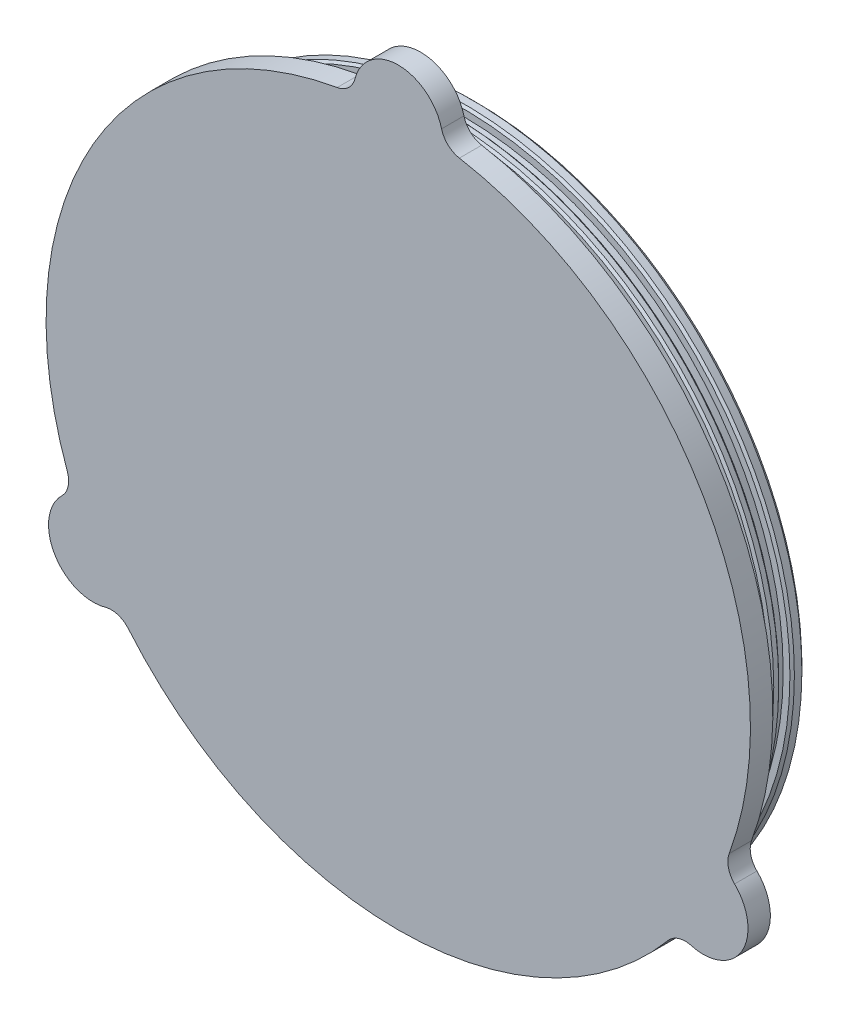
from build123d import *

# Parameters (mm, degrees)
SKETCH1_R          = 100.0125
EXTRUDE1_DEPTH     = 6.35
SKETCH2_R          = 93.6625
EXTRUDE2_DEPTH     = 15.875
SKETCH3_R          = 87.3125
CUT_EXTRUDE1_DEPTH = 15.875
SKETCH4_W          = 3.175
SKETCH4_H          = 2.54
CHAMFER1_SIZE      = 1.27
EXTRUDE3_DEPTH     = 6.35
CHAMFER2_SIZE      = 0.635
FILLET1_R          = 6.35


with BuildPart() as part:
    # Sketch1 → Extrude1 (new body)
    with BuildSketch(Plane.XY):
        Circle(SKETCH1_R)
    extrude(amount=EXTRUDE1_DEPTH)

    # Sketch2 → Extrude2 (add)
    with BuildSketch(Plane(origin=(0, 0, 0), x_dir=(-1, 0, 0), z_dir=(0, 0, -1))):
        Circle(SKETCH2_R)
    extrude(amount=EXTRUDE2_DEPTH)

    # Sketch3 → Cut-Extrude1 (cut)
    with BuildSketch(Plane(origin=(0, 0, -15.875), x_dir=(-1, 0, 0), z_dir=(0, 0, -1))):
        Circle(SKETCH3_R)
    extrude(amount=-CUT_EXTRUDE1_DEPTH, mode=Mode.SUBTRACT)

    # Sketch4 → Cut-Revolve1 (revolve, cut)
    with BuildSketch(Plane(origin=(0, 0, 0), x_dir=(0, 0, -1), z_dir=(1, 0, 0))):
        with Locations((4.395911794, 92.3925)):
            Rectangle(SKETCH4_W, SKETCH4_H)
        with Locations((10.251990741, 92.3925)):
            Rectangle(SKETCH4_W, SKETCH4_H)
    revolve(axis=Axis((0, 0, 0), (0, 0, -1)), mode=Mode.SUBTRACT)

    # Chamfer1
    chamfer1_edges = [part.edges().sort_by_distance(p)[0] for p in [
        (93.6625, 0, -15.875),
    ]]
    chamfer(chamfer1_edges, length=CHAMFER1_SIZE)

    # Sketch8 → Extrude3 (add)
    with BuildSketch(Plane.XY.offset(6.35)):
        with BuildLine():
            ThreePointArc((-12.674375762, 99.206150794), (0, 112.7125), (12.674375762, 99.206150794))
            ThreePointArc((12.674375762, 99.206150794), (0, 100.0125), (-12.674375762, 99.206150794))
        make_face()
        with BuildLine():
            ThreePointArc((92.25223468, -38.62674401), (97.611888324, -56.35625), (79.577858918, -60.579406784))
            ThreePointArc((79.577858918, -60.579406784), (86.613365696, -50.00625), (92.25223468, -38.62674401))
        make_face()
        with BuildLine():
            ThreePointArc((-92.25223468, -38.62674401), (-97.611888324, -56.35625), (-79.577858918, -60.579406784))
            ThreePointArc((-79.577858918, -60.579406784), (-86.613365696, -50.00625), (-92.25223468, -38.62674401))
        make_face()
    extrude(amount=-EXTRUDE3_DEPTH)

    # Chamfer2
    chamfer2_edges = [part.edges().sort_by_distance(p)[0] for p in [
        (93.6625, 0, -2.808411794),
        (93.6625, 0, -5.983411794),
        (93.6625, 0, -8.664490741),
        (93.6625, 0, -11.839490741),
    ]]
    chamfer(chamfer2_edges, length=CHAMFER2_SIZE)

    # Fillet1
    fillet1_edges = [part.edges().sort_by_distance(p)[0] for p in [
        (12.674375762, 99.206150794, 3.175),
        (-12.674375762, 99.206150794, 3.175),
        (79.577858918, -60.579406784, 3.175),
        (92.25223468, -38.62674401, 3.175),
        (-92.25223468, -38.62674401, 3.175),
        (-79.577858918, -60.579406784, 3.175),
    ]]
    fillet(fillet1_edges, radius=FILLET1_R)


solid = part.part
